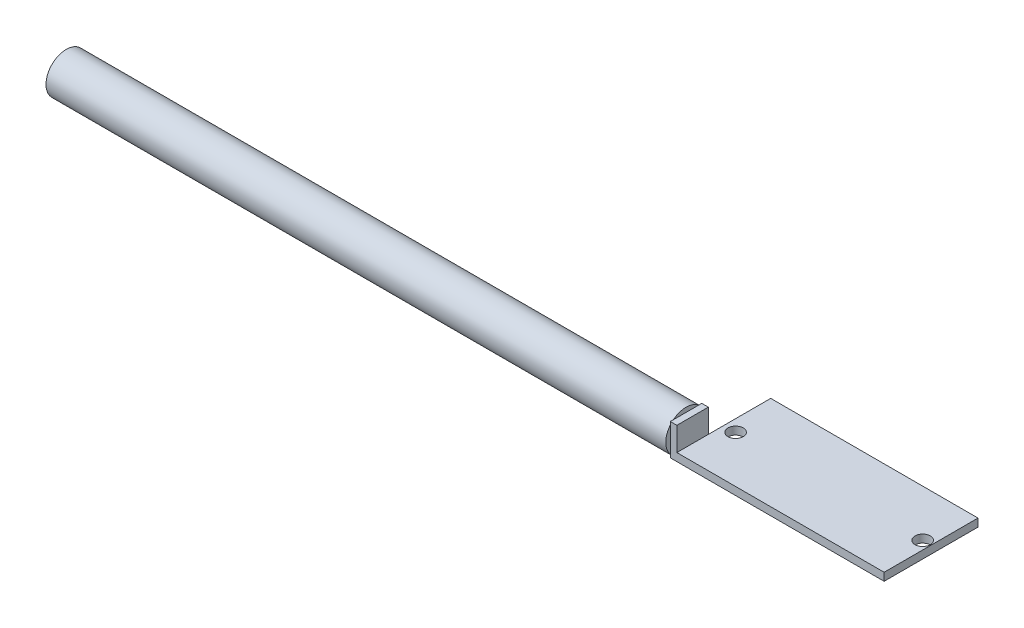
from build123d import *

# Parameters (mm, degrees)
SKETCH1_W           = 40.132
SKETCH1_H           = 18.1737
PCB_BOARD_DEPTH     = 1.524
SKETCH2_W           = 6.096
SKETCH2_H           = 6.096
BOSS_EXTRUDE1_DEPTH = 1.27
SKETCH3_R           = 3.91795
BOSS_EXTRUDE2_DEPTH = 120
SKETCH4_R           = 1.476375
CUT_EXTRUDE1_DEPTH  = 1.524


with BuildPart() as part:
    # Sketch1 → PCB board (new body)
    with BuildSketch(Plane(origin=(0, 0, 0), x_dir=(1, 0, 0), z_dir=(0, 1, 0))):
        Rectangle(SKETCH1_W, SKETCH1_H)
    extrude(amount=PCB_BOARD_DEPTH)

    # Sketch2 → Boss-Extrude1 (add)
    with BuildSketch(Plane.ZY.offset(20.066)):
        with Locations((6.03885, 3.048)):
            Rectangle(SKETCH2_W, SKETCH2_H)
    extrude(amount=BOSS_EXTRUDE1_DEPTH)

    # Sketch3 → Boss-Extrude2 (add)
    with BuildSketch(Plane.ZY.offset(21.336)):
        with Locations((6.03885, 3.048)):
            Circle(SKETCH3_R)
    extrude(amount=BOSS_EXTRUDE2_DEPTH)

    # Sketch4 → Cut-Extrude1 (cut)
    with BuildSketch(Plane(origin=(0, 1.524, 0), x_dir=(1, 0, 0), z_dir=(0, 1, 0))):
        with Locations((-17.776825, 0)):
            Circle(SKETCH4_R)
        with Locations((18.437225, 0)):
            Circle(SKETCH4_R)
    extrude(amount=-CUT_EXTRUDE1_DEPTH, mode=Mode.SUBTRACT)


solid = part.part
